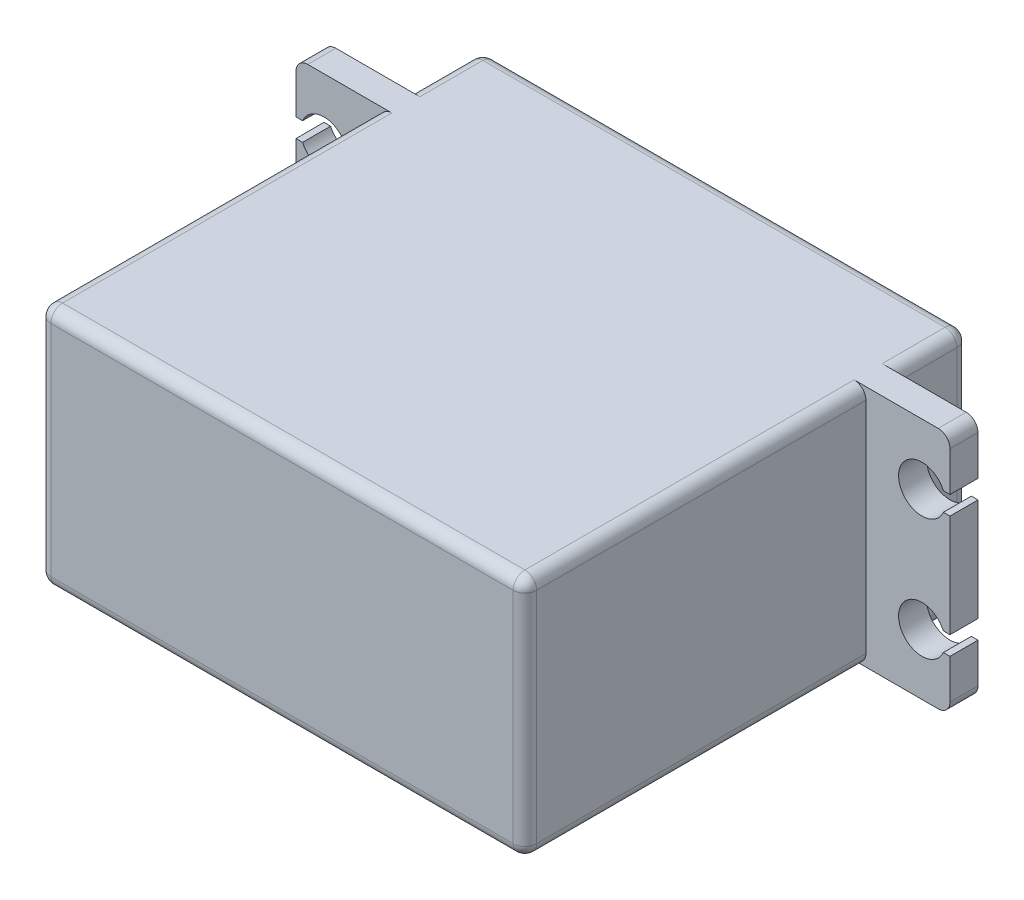
from build123d import *

# Parameters (mm, degrees)
BOSS_EXTRUDE1_DEPTH = 20.6375
CUT_EXTRUDE1_DEPTH  = 32.353125
FILLET1_R           = 1
FILLET2_R           = 1
SKETCH3_R           = 4.7625
BOSS_EXTRUDE2_DEPTH = 1.5875
FILLET3_R           = 1
SKETCH4_R           = 3.96875
BOSS_EXTRUDE3_DEPTH = 1.5875


with BuildPart() as part:
    # Sketch1 → Boss-Extrude1 (new body)
    with BuildSketch(Plane(origin=(0, 0, 0), x_dir=(1, 0, 0), z_dir=(0, 1, 0))):
        Polygon((0, 0), (-41.275, 0), (-41.275, 28.971875), (-48.41875, 28.971875), (-48.41875, 31.353125), (-41.275, 31.353125), (-41.275, 37.703125), (0, 37.703125), (0, 31.353125), (7.14375, 31.353125), (7.14375, 28.971875), (0, 28.971875), align=None)
    extrude(amount=BOSS_EXTRUDE1_DEPTH)

    # Sketch2 → Cut-Extrude1 (cut, through all)
    with BuildSketch(Plane(origin=(0, 0, -31.353125), x_dir=(-1, 0, 0), z_dir=(0, 0, -1))):
        with BuildLine():
            Line((-7.14375, 16.271875), (-6.581209729, 16.271875))
            ThreePointArc((-6.581209729, 16.271875), (-2.778125, 15.478125), (-6.581209729, 14.684375))
            Line((-6.581209729, 14.684375), (-7.14375, 14.684375))
            Line((-7.14375, 14.684375), (-7.14375, 16.271875))
        make_face()
        with BuildLine():
            Line((47.856209729, 16.271875), (48.41875, 16.271875))
            Line((48.41875, 16.271875), (48.41875, 14.684375))
            Line((48.41875, 14.684375), (47.856209729, 14.684375))
            ThreePointArc((47.856209729, 14.684375), (44.053125, 15.478125), (47.856209729, 16.271875))
        make_face()
        with BuildLine():
            Line((47.856209729, 4.365625), (48.41875, 4.365625))
            Line((48.41875, 4.365625), (48.41875, 5.953125))
            Line((48.41875, 5.953125), (47.856209729, 5.953125))
            ThreePointArc((47.856209729, 5.953125), (44.053125, 5.159375), (47.856209729, 4.365625))
        make_face()
        with BuildLine():
            Line((-7.14375, 5.953125), (-6.581209729, 5.953125))
            ThreePointArc((-6.581209729, 5.953125), (-2.778125, 5.159375), (-6.581209729, 4.365625))
            Line((-6.581209729, 4.365625), (-7.14375, 4.365625))
            Line((-7.14375, 4.365625), (-7.14375, 5.953125))
        make_face()
    extrude(amount=-CUT_EXTRUDE1_DEPTH, mode=Mode.SUBTRACT)

    # Fillet1
    fillet1_edges = [part.edges().sort_by_distance(p)[0] for p in [
        (7.14375, 20.6375, -30.1625),
        (-48.41875, 0, -30.1625),
        (7.14375, 0, -30.1625),
        (-48.41875, 20.6375, -30.1625),
    ]]
    fillet(fillet1_edges, radius=FILLET1_R)

    # Fillet2
    fillet2_edges = [part.edges().sort_by_distance(p)[0] for p in [
        (-20.6375, 0, 0),
        (-41.275, 0, -14.4859375),
        (-41.275, 0, -34.528125),
        (-20.6375, 0, -37.703125),
        (0, 0, -34.528125),
        (0, 0, -14.4859375),
        (0, 20.6375, -34.528125),
        (-20.6375, 20.6375, -37.703125),
        (0, 10.31875, 0),
        (-41.275, 10.31875, 0),
        (-41.275, 10.31875, -37.703125),
        (0, 10.31875, -37.703125),
        (-41.275, 20.6375, -34.528125),
        (-41.275, 20.6375, -14.4859375),
        (-20.6375, 20.6375, 0),
        (0, 20.6375, -14.4859375),
    ]]
    fillet(fillet2_edges, radius=FILLET2_R)

    # Sketch3 → Boss-Extrude2 (add)
    with BuildSketch(Plane(origin=(0, 0, -37.703125), x_dir=(-1, 0, 0), z_dir=(0, 0, -1))):
        with Locations((10.286875, 10.31875)):
            Circle(SKETCH3_R)
    extrude(amount=BOSS_EXTRUDE2_DEPTH)

    # Fillet3
    fillet3_edges = [part.edges().sort_by_distance(p)[0] for p in [
        (-5.524375, 10.31875, -37.703125),
    ]]
    fillet(fillet3_edges, radius=FILLET3_R)

    # Sketch4 → Boss-Extrude3 (add)
    with BuildSketch(Plane(origin=(0, 0, -39.290625), x_dir=(-1, 0, 0), z_dir=(0, 0, -1))):
        with Locations((10.286875, 10.31875)):
            Circle(SKETCH4_R)
    extrude(amount=BOSS_EXTRUDE3_DEPTH)


solid = part.part
